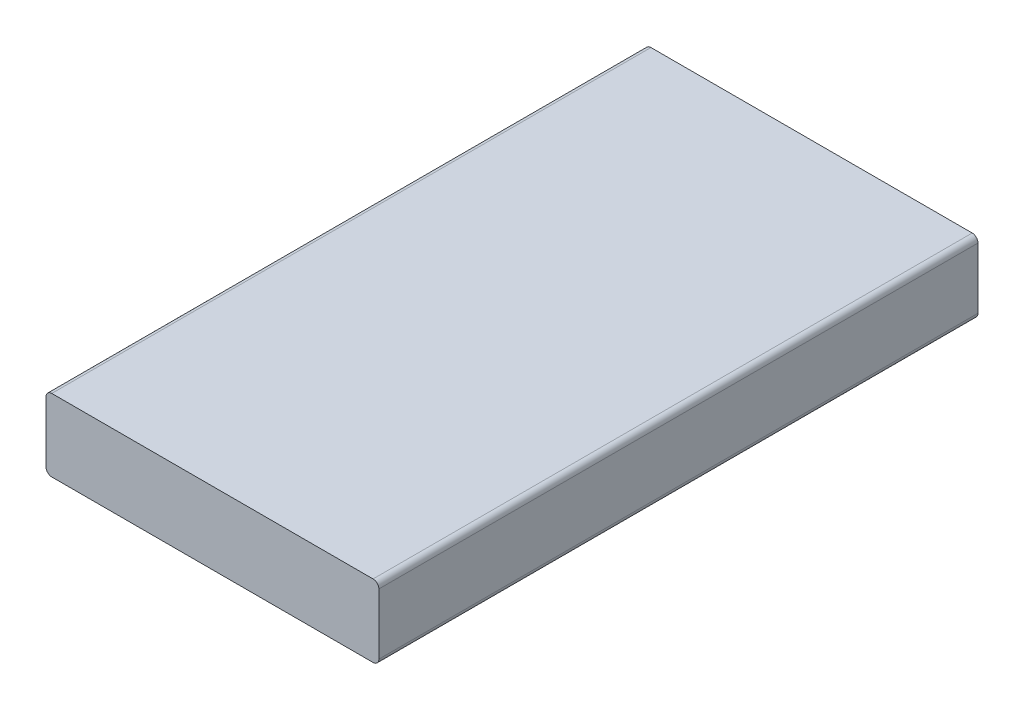
from build123d import *

# Parameters (mm, degrees)
SKETCH1_W           = 115
SKETCH1_H           = 25
BOSS_EXTRUDE1_DEPTH = 207
FILLET1_R           = 2


with BuildPart() as part:
    # Sketch1 → Boss-Extrude1 (new body)
    with BuildSketch(Plane.XY):
        with Locations((28.159722222, 3.385416667)):
            Rectangle(SKETCH1_W, SKETCH1_H)
    extrude(amount=-BOSS_EXTRUDE1_DEPTH)

    # Fillet1
    fillet1_edges = [part.edges().sort_by_distance(p)[0] for p in [
        (-29.340277778, 15.885416667, -103.5),
        (85.659722222, 15.885416667, -103.5),
        (85.659722222, -9.114583333, -103.5),
        (-29.340277778, -9.114583333, -103.5),
    ]]
    fillet(fillet1_edges, radius=FILLET1_R)


solid = part.part
